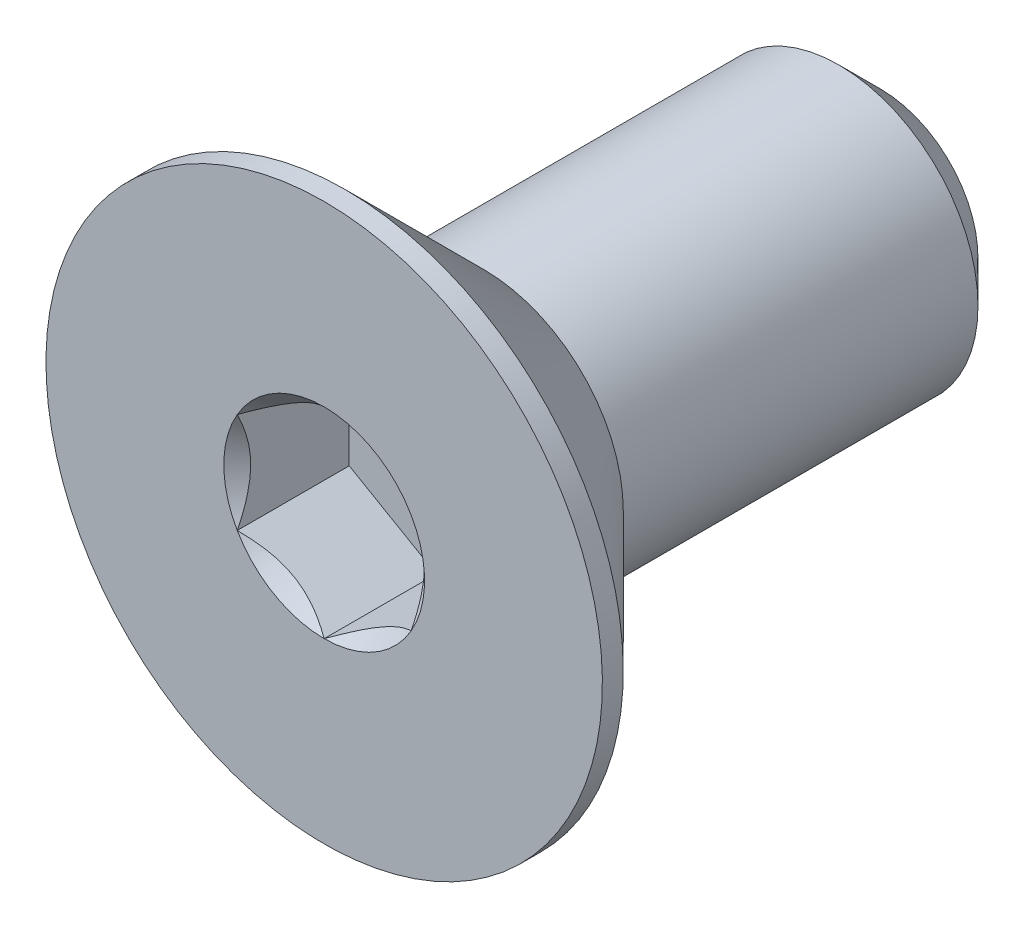
from build123d import *

# Parameters (mm, degrees)
SKETCH3_W          = 8
SKETCH3_H          = 2
CHAMFER1_SIZE      = 0.6
CUT_EXTRUDE1_DEPTH = 1.61
SKETCH9_R          = 1.443375673
CUT_EXTRUDE2_DEPTH = 1.61
CUT_EXTRUDE2_DRAFT = -45


with BuildPart() as part:
    # Sketch3 → Revolve1 (revolve)
    with BuildSketch(Plane(origin=(0, 0, 0), x_dir=(0, 0, -1), z_dir=(1, 0, 0))):
        with Locations((0, 1)):
            Rectangle(SKETCH3_W, SKETCH3_H)
    revolve(axis=Axis((0, 0, -4), (0, 0, 1)))

    # Chamfer1
    chamfer1_edges = [part.edges().sort_by_distance(p)[0] for p in [
        (0, -2, -4),
    ]]
    chamfer(chamfer1_edges, length=CHAMFER1_SIZE)

    # Sketch6 → Revolve2 (revolve)
    with BuildSketch(Plane(origin=(0, 0, 0), x_dir=(0, 0, -1), z_dir=(1, 0, 0))):
        Polygon((-4, 4), (-3.7, 4), (-1.7, 2), (-1.7, 0), (-4, 0), align=None)
    revolve(axis=Axis((0, 0, -4), (0, 0, 1)))

    # Sketch8 → Cut-Extrude1 (cut)
    with BuildSketch(Plane.XY.offset(4)):
        Polygon((0, 1.443375673), (-1.25, 0.721687836), (-1.25, -0.721687836), (0, -1.443375673), (1.25, -0.721687836), (1.25, 0.721687836), align=None)
    extrude(amount=-CUT_EXTRUDE1_DEPTH, mode=Mode.SUBTRACT)


with BuildPart() as cut_extrude2_tool:
    # Sketch9 → Cut-Extrude2 (with draft: the straight prism first)
    with BuildSketch(Plane.XY.offset(4)):
        Circle(SKETCH9_R)
    extrude(amount=-CUT_EXTRUDE2_DEPTH)
    # Cut-Extrude2: the draft: its side faces are tilted about the plane it starts from
    cut_extrude2_sides = [cut_extrude2_tool.faces().sort_by_distance(p)[0] for p in [
        (-1.443375673, 0, 3.195),
    ]]
    draft(cut_extrude2_sides, Plane.XY.offset(4), CUT_EXTRUDE2_DRAFT)


with BuildPart() as part_1:
    add(part.part)

    # Cut-Extrude2: cut by cut_extrude2_tool
    add(cut_extrude2_tool.part, mode=Mode.SUBTRACT)


solid = part_1.part
